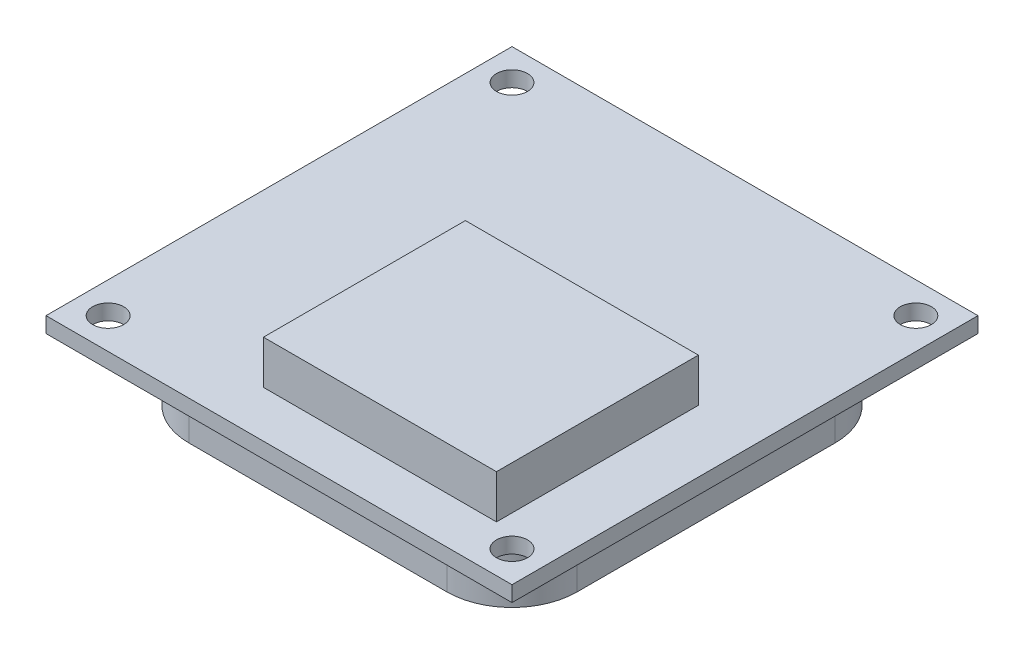
from build123d import *

# Parameters (mm, degrees)
SKETCH1_W           = 30
SKETCH1_H           = 30
SKETCH1_R           = 1
BOSS_EXTRUDE2_DEPTH = 1
SKETCH2_W           = 15
SKETCH2_H           = 13
BOSS_EXTRUDE3_DEPTH = 2.8
BOSS_EXTRUDE4_DEPTH = 4


with BuildPart() as part:
    # Sketch1 → Boss-Extrude2 (new body)
    with BuildSketch(Plane(origin=(0, 0, 0), x_dir=(1, 0, 0), z_dir=(0, 1, 0))):
        with Locations((2.382352941, -5.426470588)):
            Rectangle(SKETCH1_W, SKETCH1_H)
        with Locations(Location((-10.617647059, 7.573529412, 0), (0, 0, 270))):  # turned: the seam where the file's is
            Circle(SKETCH1_R, mode=Mode.SUBTRACT)
        with Locations(Location((15.382352941, 7.573529412, 0), (0, 0, 270))):  # turned: the seam where the file's is
            Circle(SKETCH1_R, mode=Mode.SUBTRACT)
        with Locations(Location((15.382352941, -18.426470588, 0), (0, 0, 270))):  # turned: the seam where the file's is
            Circle(SKETCH1_R, mode=Mode.SUBTRACT)
        with Locations(Location((-10.617647059, -18.426470588, 0), (0, 0, 270))):  # turned: the seam where the file's is
            Circle(SKETCH1_R, mode=Mode.SUBTRACT)
    extrude(amount=BOSS_EXTRUDE2_DEPTH)

    # Sketch2 → Boss-Extrude3 (add)
    with BuildSketch(Plane(origin=(0, 1, 0), x_dir=(1, 0, 0), z_dir=(0, 1, 0))):
        with Locations((5.882352941, -10.926470588)):
            Rectangle(SKETCH2_W, SKETCH2_H)
    extrude(amount=BOSS_EXTRUDE3_DEPTH)

    # Sketch3 → Boss-Extrude4 (add)
    with BuildSketch(Plane.XZ):
        with BuildLine():
            Line((-5.926151738, 17.926470588), (10.69085762, 17.926470588))
            ThreePointArc((10.69085762, 17.926470588), (13.654692385, 16.698810032), (14.882352941, 13.734975267))
            Line((14.882352941, 13.734975267), (14.882352941, -2.882034091))
            ThreePointArc((14.882352941, -2.882034091), (13.654692385, -5.845868856), (10.69085762, -7.073529412))
            Line((10.69085762, -7.073529412), (-5.926151738, -7.073529412))
            ThreePointArc((-5.926151738, -7.073529412), (-8.889986503, -5.845868856), (-10.117647059, -2.882034091))
            Line((-10.117647059, -2.882034091), (-10.117647059, 13.734975267))
            ThreePointArc((-10.117647059, 13.734975267), (-8.889986503, 16.698810032), (-5.926151738, 17.926470588))
        make_face()
    extrude(amount=BOSS_EXTRUDE4_DEPTH)


solid = part.part
